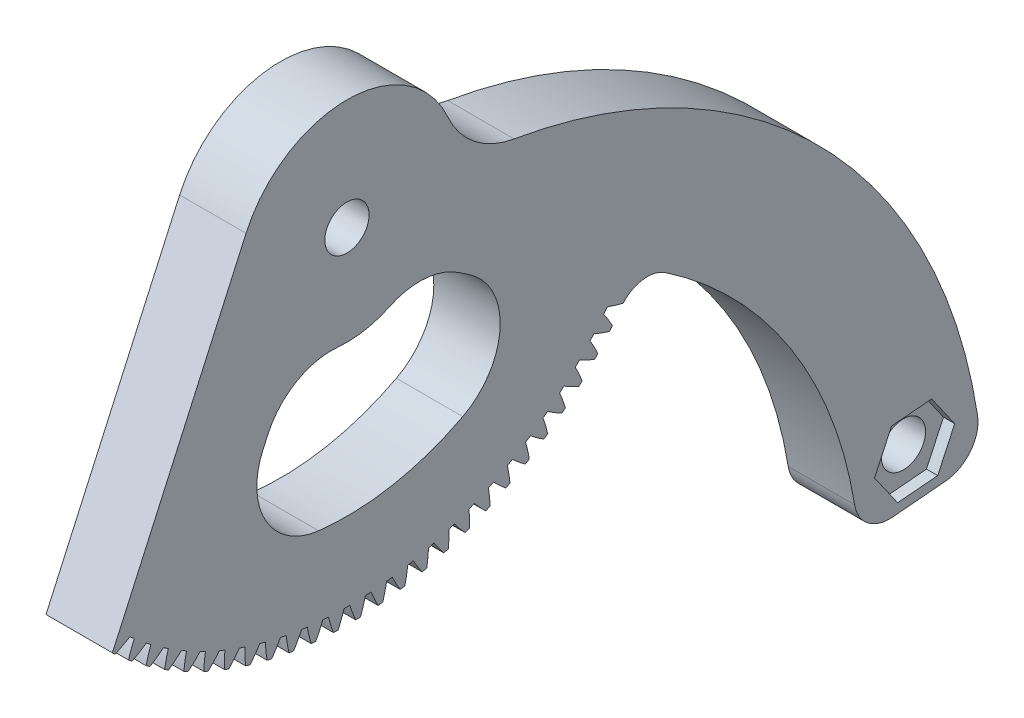
from build123d import *

# Parameters (mm, degrees)
BASPROSKE_W             = 12.7
BASPROSKE_H             = 49
TOOTHCUT_DEPTH          = 71.450621005
TEETHCUTS_COUNT         = 96
BORSKE_R                = 0.4
BORE_DEPTH              = 50.0000508
CORTAR_EXTRUIR1_DEPTH   = 71.427720324
SALIENTE_EXTRUIR1_DEPTH = 12.7
CROQUIS4_R              = 3.175
CORTAR_EXTRUIR2_DEPTH   = 119.085472642
CORTAR_EXTRUIR3_DEPTH   = 3.2
CORTAR_EXTRUIR4_REACH   = 120.085
CORTAR_EXTRUIR5_DEPTH   = 1.5875


with BuildPart() as part:
    # BasProSke → Base-Revolve (revolve)
    with BuildSketch(Plane(origin=(0, 0, 0), x_dir=(1, 0, 0), z_dir=(0, 1, 0)), mode=Mode.PRIVATE) as base_revolve_sk:
        with Locations((6.35, 24.5)):
            Rectangle(BASPROSKE_W, BASPROSKE_H)
    revolve(base_revolve_sk.sketch.rotate(Axis((-10, 0, 0), (1, 0, 0)), 180), axis=Axis((-10, 0, 0), (1, 0, 0)))

    # TooCutSke → ToothCut (cut, through all)
    with BuildSketch(Plane(origin=(0, 0, 0), x_dir=(0, 0, -1), z_dir=(1, 0, 0))):
        with BuildLine():
            ThreePointArc((0.415666164, 46.747152027), (0, 46.749), (-0.415666164, 46.747152027))
            ThreePointArc((-0.415666164, 46.747152027), (-0.812912529, 47.891564186), (-1.28153738, 49.008647269))
            ThreePointArc((-1.28153738, 49.008647269), (0, 49.0254), (1.28153738, 49.008647269))
            ThreePointArc((1.28153738, 49.008647269), (0.812912529, 47.891564186), (0.415666164, 46.747152027))
        make_face()
    toothcut = extrude(amount=TOOTHCUT_DEPTH, mode=Mode.SUBTRACT)

    # TeethCuts: ToothCut ×96 about axis
    teethcuts_axis = Axis((0, 0, 0), (1, 0, 0))
    for i in range(1, TEETHCUTS_COUNT):
        add(toothcut.rotate(teethcuts_axis, i * 360 / TEETHCUTS_COUNT), mode=Mode.SUBTRACT)

    # BorSke → Bore (cut, symmetric)
    with BuildSketch(Plane(origin=(0, 0, 0), x_dir=(0, 0, -1), z_dir=(1, 0, 0))):
        with Locations(Location((0, 0, 0), (0, 0, 180))):
            Circle(BORSKE_R)
    extrude(amount=BORE_DEPTH, both=True, mode=Mode.SUBTRACT)

    # Croquis2 → Cortar-Extruir1 (cut, through all)
    with BuildSketch(Plane(origin=(12.7, 0, 0), x_dir=(0, 0, -1), z_dir=(1, 0, 0))):
        with BuildLine():
            ThreePointArc((23.984655986, -0.583157257), (36.524600052, -3.793553196), (48.395867777, -8.953964212))
            ThreePointArc((48.395867777, -8.953964212), (-15.236757781, 47.277477286), (-33.647532421, -35.62083045))
            Line((-33.647532421, -35.62083045), (-14.472949427, 6.922987037))
            ThreePointArc((-14.472949427, 6.922987037), (0.063742892, 16.274872026), (14.524865824, 6.806551162))
            ThreePointArc((14.524865824, 6.806551162), (18.326573639, 1.923496246), (23.984655986, -0.583157257))
        make_face()
    extrude(amount=-CORTAR_EXTRUIR1_DEPTH, mode=Mode.SUBTRACT)

    # Croquis3 → Saliente-Extruir1 (add, through all)
    with BuildSketch(Plane(origin=(12.7, 0, 0), x_dir=(0, 0, -1), z_dir=(1, 0, 0))):
        with BuildLine():
            Line((78.291342391, -74.718112999), (85.901159176, -74.052340298))
            ThreePointArc((85.901159176, -74.052340298), (89.456654772, -72.12542661), (90.47830187, -68.212527108))
            ThreePointArc((90.47830187, -68.212527108), (68.118235351, -23.693910917), (23.984655986, -0.583157257))
            Line((23.984655986, -0.583157257), (26.101585902, -24.779776923))
            Line((26.101585902, -24.779776923), (39.634428828, -28.811665198))
            ThreePointArc((39.634428828, -28.811665198), (42.509448117, -27.287465547), (45.67542899, -28.039453308))
            ThreePointArc((45.67542899, -28.039453308), (63.643556946, -46.447865582), (72.834621498, -70.473843129))
            ThreePointArc((72.834621498, -70.473843129), (74.729702565, -73.667298489), (78.291342391, -74.718112999))
        make_face()
    extrude(amount=-SALIENTE_EXTRUIR1_DEPTH)

    # Croquis4 → Cortar-Extruir2 (cut, through all)
    with BuildSketch(Plane(origin=(12.7, 0, 0), x_dir=(0, 0, -1), z_dir=(1, 0, 0))):
        with Locations((0, 0.4)):
            Circle(CROQUIS4_R)
        with Locations((81.443110483, -68.068113052)):
            Circle(CROQUIS4_R)
    extrude(amount=-CORTAR_EXTRUIR2_DEPTH, mode=Mode.SUBTRACT)

    # Croquis5 → Cortar-Extruir3 (cut)
    with BuildSketch(Plane(origin=(12.7, 0, 0), x_dir=(0, 0, -1), z_dir=(1, 0, 0))):
        Polygon((83.883098155, -62.835542604), (78.131565384, -63.338736519), (75.691577712, -68.571306967), (79.003122811, -73.3006835), (84.754655582, -72.797489585), (87.194643254, -67.564919137), align=None)
    extrude(amount=-CORTAR_EXTRUIR3_DEPTH, mode=Mode.SUBTRACT)

    # Croquis7 → Cortar-Extruir4 (cut, up to next)
    with BuildSketch(Plane(origin=(12.7, 0, 0), x_dir=(0, 0, -1), z_dir=(1, 0, 0)), mode=Mode.PRIVATE) as cortar_extruir4_sk1:
        with BuildLine():
            Line((-12.043509039, -21.205573528), (-11.34750433, -19.661305404))
            ThreePointArc((-11.34750433, -19.661305404), (-7.265854644, -15.130419761), (-1.311686645, -13.812591127))
            ThreePointArc((-1.311686645, -13.812591127), (2.507089623, -13.651077183), (6.146076318, -12.481925876))
            ThreePointArc((6.146076318, -12.481925876), (11.180043593, -11.533837901), (16.023017706, -13.202759435))
            Line((16.023017706, -13.202759435), (17.558094048, -14.232517981))
            ThreePointArc((17.558094048, -14.232517981), (21.972312698, -23.083283528), (16.61899696, -31.399736358))
            ThreePointArc((16.61899696, -31.399736358), (6.569206228, -34.874067272), (-4.057535802, -35.250395448))
            ThreePointArc((-4.057535802, -35.250395448), (-11.619670959, -30.257424581), (-12.043509039, -21.205573528))
        make_face()
    cortar_extruir4_tool1 = extrude(cortar_extruir4_sk1.sketch, amount=-CORTAR_EXTRUIR4_REACH, mode=Mode.PRIVATE) & part.part
    add(cortar_extruir4_tool1.solids().sort_by_distance((12.7, -23.759091, -4.457005))[0], mode=Mode.SUBTRACT)

    # Croquis8 → Cortar-Extruir5 (cut)
    with BuildSketch(Plane(origin=(12.7, 0, 0), x_dir=(0, 0, -1), z_dir=(1, 0, 0))):
        with BuildLine():
            Line((78.291342391, -74.718112999), (85.901159176, -74.052340298))
            ThreePointArc((85.901159176, -74.052340298), (89.456654772, -72.12542661), (90.47830187, -68.212527108))
            ThreePointArc((90.47830187, -68.212527108), (68.118235351, -23.693910917), (23.984655986, -0.583157257))
            ThreePointArc((23.984655986, -0.583157257), (18.326573639, 1.923496246), (14.524865824, 6.806551162))
            ThreePointArc((14.524865824, 6.806551162), (0.063742892, 16.274872026), (-14.472949427, 6.922987037))
            Line((-14.472949427, 6.922987037), (-33.647532421, -35.62083045))
            ThreePointArc((-33.647532421, -35.62083045), (-33.450270144, -35.806136727), (-33.251987351, -35.990350613))
            ThreePointArc((-33.251987351, -35.990350613), (-32.176077274, -35.46435344), (-31.135053426, -34.872302035))
            ThreePointArc((-31.135053426, -34.872302035), (-30.82375751, -35.14775916), (-30.510024688, -35.420437526))
            ThreePointArc((-30.510024688, -35.420437526), (-30.961130133, -36.529833486), (-31.342192881, -37.665195411))
            ThreePointArc((-31.342192881, -37.665195411), (-31.085270924, -37.877512215), (-30.826910741, -38.088076535))
            ThreePointArc((-30.826910741, -38.088076535), (-29.787706131, -37.492837677), (-28.78763321, -36.833967682))
            ThreePointArc((-28.78763321, -36.833967682), (-28.458988045, -37.088475305), (-28.12809293, -37.340050738))
            ThreePointArc((-28.12809293, -37.340050738), (-28.505674557, -38.476575104), (-28.811665198, -39.634428828))
            ThreePointArc((-28.811665198, -39.634428828), (-28.541407147, -39.829487545), (-28.269828567, -40.022703467))
            ThreePointArc((-28.269828567, -40.022703467), (-27.271779458, -39.360771828), (-26.316939929, -38.637904625))
            ThreePointArc((-26.316939929, -38.637904625), (-25.972352823, -38.870372906), (-25.62571236, -39.09976812))
            ThreePointArc((-25.62571236, -39.09976812), (-25.928153306, -40.25855412), (-26.15776154, -41.433941536))
            ThreePointArc((-26.15776154, -41.433941536), (-25.875324682, -41.610906895), (-25.591690647, -41.785947037))
            ThreePointArc((-25.591690647, -41.785947037), (-24.639070838, -41.06015711), (-23.733553471, -40.276388128))
            ThreePointArc((-23.733553471, -40.276388128), (-23.3745, -40.485821602), (-23.013598556, -40.692054292))
            ThreePointArc((-23.013598556, -40.692054292), (-23.239603721, -41.868139827), (-23.391846332, -43.056027745))
            ThreePointArc((-23.391846332, -43.056027745), (-23.098440104, -43.214141953), (-22.803965179, -43.370256768))
            ThreePointArc((-22.803965179, -43.370256768), (-21.900853935, -42.583716496), (-21.048536294, -41.742401954))
            ThreePointArc((-21.048536294, -41.742401954), (-20.676553979, -41.927903794), (-20.302936989, -42.110090841))
            ThreePointArc((-20.302936989, -42.110090841), (-20.451538586, -43.298439731), (-20.525763647, -44.493741433))
            ThreePointArc((-20.525763647, -44.493741433), (-20.22264446, -44.632327421), (-19.918589631, -44.768848401))
            ThreePointArc((-19.918589631, -44.768848401), (-19.068854212, -43.92492587), (-18.273386052, -43.029668407))
            ThreePointArc((-18.273386052, -43.029668407), (-17.89006778, -43.190444265), (-17.50533513, -43.347805515))
            ThreePointArc((-17.50533513, -43.347805515), (-17.575896823, -44.543329069), (-17.57178649, -45.74092609))
            ThreePointArc((-17.57178649, -45.74092609), (-17.260252348, -45.859390411), (-16.947919624, -45.975732951))
            ThreePointArc((-16.947919624, -45.975732951), (-16.155198728, -45.078041968), (-15.419986367, -44.132675213))
            ThreePointArc((-15.419986367, -44.132675213), (-15.026973563, -44.268036624), (-14.632772738, -44.399898232))
            ThreePointArc((-14.632772738, -44.399898232), (-14.624992371, -45.597477033), (-14.542564246, -46.792241078))
            ThreePointArc((-14.542564246, -46.792241078), (-14.223949185, -46.890076451), (-13.904676024, -46.985742355))
            ThreePointArc((-13.904676024, -46.985742355), (-13.172364203, -46.038126971), (-12.500555932, -45.046699129))
            ThreePointArc((-12.500555932, -45.046699129), (-12.099531539, -45.156066453), (-11.697550566, -45.261863768))
            ThreePointArc((-11.697550566, -45.261863768), (-11.611461457, -46.456369601), (-11.45106851, -47.643184507))
            ThreePointArc((-11.45106851, -47.643184507), (-11.126736889, -47.719971985), (-10.801890466, -47.794551597))
            ThreePointArc((-10.801890466, -47.794551597), (-10.133123593, -46.801069645), (-9.527596197, -45.767826163))
            ThreePointArc((-9.527596197, -45.767826163), (-9.120277464, -45.850731074), (-8.712237687, -45.930011055))
            ThreePointArc((-8.712237687, -45.930011055), (-8.548208482, -47.116328862), (-8.31053754, -48.290112506))
            ThreePointArc((-8.31053754, -48.290112506), (-7.981878196, -48.345523272), (-7.652849554, -48.398697231))
            ThreePointArc((-7.652849554, -48.398697231), (-7.050491391, -47.363602954), (-6.513837834, -46.292968339))
            ThreePointArc((-6.513837834, -46.292968339), (-6.10196896, -46.349055824), (-5.689617669, -46.401478983))
            ThreePointArc((-5.689617669, -46.401478983), (-5.448350766, -47.574528769), (-5.134419572, -48.730254829))
            ThreePointArc((-5.134419572, -48.730254829), (-4.802839876, -48.764051607), (-4.471037966, -48.795592214))
            ThreePointArc((-4.471037966, -48.795592214), (-3.937667903, -47.723318044), (-3.472186216, -46.619876918))
            ThreePointArc((-3.472186216, -46.619876918), (-3.057530888, -46.648906802), (-2.642633834, -46.674248654))
            ThreePointArc((-2.642633834, -46.674248654), (-2.325162376, -47.82900724), (-1.936315232, -48.961726719))
            ThreePointArc((-1.936315232, -48.961726719), (-1.603235058, -48.973764786), (-1.270080708, -48.983536979))
            ThreePointArc((-1.270080708, -48.983536979), (-0.807982717, -47.87867456), (-0.415666164, -46.747152027))
            ThreePointArc((-0.415666164, -46.747152027), (0, -46.749), (0.415666164, -46.747152027))
            ThreePointArc((0.415666164, -46.747152027), (0.807982717, -47.87867456), (1.270080708, -48.983536979))
            ThreePointArc((1.270080708, -48.983536979), (1.603235058, -48.973764786), (1.936315232, -48.961726719))
            ThreePointArc((1.936315232, -48.961726719), (2.325162376, -47.82900724), (2.642633834, -46.674248654))
            ThreePointArc((2.642633834, -46.674248654), (3.057530888, -46.648906802), (3.472186216, -46.619876918))
            ThreePointArc((3.472186216, -46.619876918), (3.937667903, -47.723318044), (4.471037966, -48.795592214))
            ThreePointArc((4.471037966, -48.795592214), (4.802839876, -48.764051607), (5.134419572, -48.730254829))
            ThreePointArc((5.134419572, -48.730254829), (5.448350766, -47.574528769), (5.689617669, -46.401478983))
            ThreePointArc((5.689617669, -46.401478983), (6.10196896, -46.349055824), (6.513837834, -46.292968339))
            ThreePointArc((6.513837834, -46.292968339), (7.050491391, -47.363602954), (7.652849554, -48.398697231))
            ThreePointArc((7.652849554, -48.398697231), (7.981878196, -48.345523272), (8.31053754, -48.290112506))
            ThreePointArc((8.31053754, -48.290112506), (8.548208482, -47.116328862), (8.712237687, -45.930011055))
            ThreePointArc((8.712237687, -45.930011055), (9.120277464, -45.850731074), (9.527596197, -45.767826163))
            ThreePointArc((9.527596197, -45.767826163), (10.133123593, -46.801069645), (10.801890466, -47.794551597))
            ThreePointArc((10.801890466, -47.794551597), (11.126736889, -47.719971985), (11.45106851, -47.643184507))
            ThreePointArc((11.45106851, -47.643184507), (11.611461457, -46.456369601), (11.697550566, -45.261863768))
            ThreePointArc((11.697550566, -45.261863768), (12.099531539, -45.156066453), (12.500555932, -45.046699129))
            ThreePointArc((12.500555932, -45.046699129), (13.172364203, -46.038126971), (13.904676024, -46.985742355))
            ThreePointArc((13.904676024, -46.985742355), (14.223949185, -46.890076451), (14.542564246, -46.792241078))
            ThreePointArc((14.542564246, -46.792241078), (14.624992371, -45.597477033), (14.632772738, -44.399898232))
            ThreePointArc((14.632772738, -44.399898232), (15.026973563, -44.268036624), (15.419986367, -44.132675213))
            ThreePointArc((15.419986367, -44.132675213), (16.155198728, -45.078041968), (16.947919624, -45.975732951))
            ThreePointArc((16.947919624, -45.975732951), (17.260252348, -45.859390411), (17.57178649, -45.74092609))
            ThreePointArc((17.57178649, -45.74092609), (17.575896823, -44.543329069), (17.50533513, -43.347805515))
            ThreePointArc((17.50533513, -43.347805515), (17.89006778, -43.190444265), (18.273386052, -43.029668407))
            ThreePointArc((18.273386052, -43.029668407), (19.068854212, -43.92492587), (19.918589631, -44.768848401))
            ThreePointArc((19.918589631, -44.768848401), (20.22264446, -44.632327421), (20.525763647, -44.493741433))
            ThreePointArc((20.525763647, -44.493741433), (20.451538586, -43.298439731), (20.302936989, -42.110090841))
            ThreePointArc((20.302936989, -42.110090841), (20.676553979, -41.927903794), (21.048536294, -41.742401954))
            ThreePointArc((21.048536294, -41.742401954), (21.900853935, -42.583716496), (22.803965179, -43.370256768))
            ThreePointArc((22.803965179, -43.370256768), (23.098440104, -43.214141953), (23.391846332, -43.056027745))
            ThreePointArc((23.391846332, -43.056027745), (23.239603721, -41.868139827), (23.013598556, -40.692054292))
            ThreePointArc((23.013598556, -40.692054292), (23.3745, -40.485821602), (23.733553471, -40.276388128))
            ThreePointArc((23.733553471, -40.276388128), (24.639070838, -41.06015711), (25.591690647, -41.785947037))
            ThreePointArc((25.591690647, -41.785947037), (25.875324682, -41.610906895), (26.15776154, -41.433941536))
            ThreePointArc((26.15776154, -41.433941536), (25.928153306, -40.25855412), (25.62571236, -39.09976812))
            ThreePointArc((25.62571236, -39.09976812), (25.972352823, -38.870372906), (26.316939929, -38.637904625))
            ThreePointArc((26.316939929, -38.637904625), (27.271779458, -39.360771828), (28.269828567, -40.022703467))
            ThreePointArc((28.269828567, -40.022703467), (28.541407147, -39.829487545), (28.811665198, -39.634428828))
            ThreePointArc((28.811665198, -39.634428828), (28.505674557, -38.476575104), (28.12809293, -37.340050738))
            ThreePointArc((28.12809293, -37.340050738), (28.458988045, -37.088475305), (28.78763321, -36.833967682))
            ThreePointArc((28.78763321, -36.833967682), (29.787706131, -37.492837677), (30.826910741, -38.088076535))
            ThreePointArc((30.826910741, -38.088076535), (31.085270924, -37.877512215), (31.342192881, -37.665195411))
            ThreePointArc((31.342192881, -37.665195411), (30.961130133, -36.529833486), (30.510024688, -35.420437526))
            ThreePointArc((30.510024688, -35.420437526), (30.82375751, -35.14775916), (31.135053426, -34.872302035))
            ThreePointArc((31.135053426, -34.872302035), (32.176077274, -35.46435344), (33.251987351, -35.990350613))
            ThreePointArc((33.251987351, -35.990350613), (33.496022799, -35.763339562), (33.738508484, -35.534673845))
            ThreePointArc((33.738508484, -35.534673845), (33.284005397, -34.426665513), (32.761307836, -33.349148563))
            ThreePointArc((32.761307836, -33.349148563), (33.056534914, -33.056534914), (33.349148563, -32.761307836))
            ThreePointArc((33.349148563, -32.761307836), (34.426665513, -33.284005397), (35.534673845, -33.738508484))
            ThreePointArc((35.534673845, -33.738508484), (35.763339562, -33.496022799), (35.990350613, -33.251987351))
            ThreePointArc((35.990350613, -33.251987351), (35.46435344, -32.176077274), (34.872302035, -31.135053426))
            ThreePointArc((34.872302035, -31.135053426), (35.14775916, -30.82375751), (35.420437526, -30.510024688))
            ThreePointArc((35.420437526, -30.510024688), (36.529833486, -30.961130133), (37.665195411, -31.342192881))
            ThreePointArc((37.665195411, -31.342192881), (37.877512215, -31.085270924), (38.088076535, -30.826910741))
            ThreePointArc((38.088076535, -30.826910741), (37.492837677, -29.787706131), (36.833967682, -28.78763321))
            ThreePointArc((36.833967682, -28.78763321), (37.088475305, -28.458988045), (37.340050738, -28.12809293))
            ThreePointArc((37.340050738, -28.12809293), (38.476575104, -28.505674557), (39.634428828, -28.811665198))
            ThreePointArc((39.634428828, -28.811665198), (42.509448117, -27.287465547), (45.67542899, -28.039453308))
            ThreePointArc((45.67542899, -28.039453308), (63.643556946, -46.447865582), (72.834621498, -70.473843129))
            ThreePointArc((72.834621498, -70.473843129), (74.729702565, -73.667298489), (78.291342391, -74.718112999))
        make_face()
    cortar_extruir5 = extrude(amount=-CORTAR_EXTRUIR5_DEPTH, mode=Mode.SUBTRACT)

    # Simetría1: Cortar-Extruir5 across plane
    add(cortar_extruir5.mirror(Plane(origin=(6.35, 0, 0), x_dir=(0, 0, 1), z_dir=(1, 0, 0))), mode=Mode.SUBTRACT)


solid = part.part
